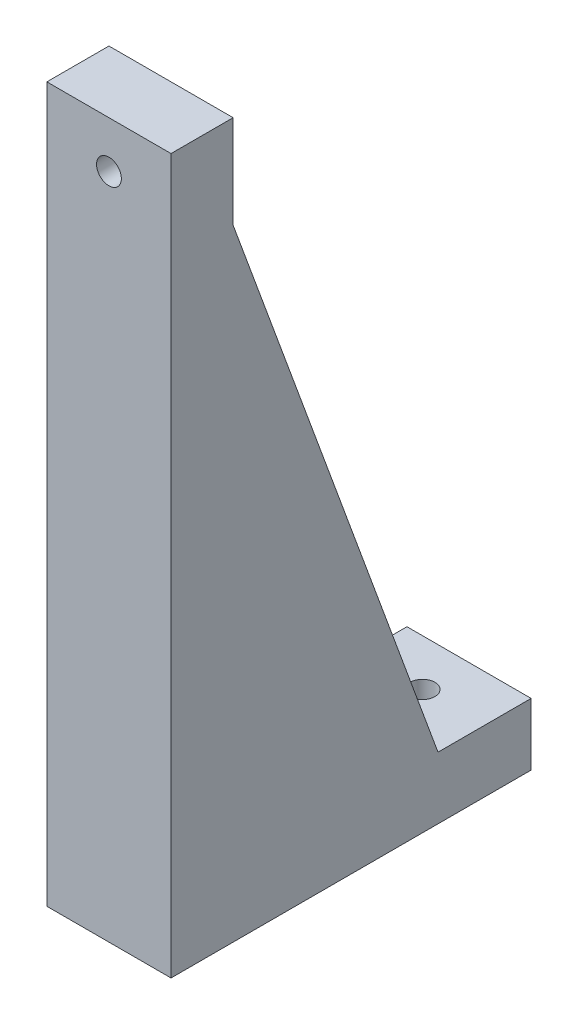
from build123d import *

# Parameters (mm, degrees)
BOSS_EXTRUDE1_DEPTH = 25.4
SKETCH2_R           = 2.54
CUT_EXTRUDE1_DEPTH  = 13.7
SKETCH3_R           = 2.54
CUT_EXTRUDE2_DEPTH  = 13.7


with BuildPart() as part:
    # Sketch1 → Boss-Extrude1 (new body)
    with BuildSketch(Plane(origin=(0, 0, 0), x_dir=(0, 0, -1), z_dir=(1, 0, 0))):
        Polygon((0, 0), (0, 146.05), (12.7, 146.05), (12.7, 127), (54.61, 12.7), (73.66, 12.7), (73.66, 0), align=None)
    extrude(amount=BOSS_EXTRUDE1_DEPTH)

    # Sketch2 → Cut-Extrude1 (cut, through all)
    with BuildSketch(Plane(origin=(0, 0, -12.7), x_dir=(-1, 0, 0), z_dir=(0, 0, -1))):
        with Locations((-12.7, 136.525)):
            Circle(SKETCH2_R)
    extrude(amount=-CUT_EXTRUDE1_DEPTH, mode=Mode.SUBTRACT)

    # Sketch3 → Cut-Extrude2 (cut, through all)
    with BuildSketch(Plane(origin=(0, 12.7, 0), x_dir=(1, 0, 0), z_dir=(0, 1, 0))):
        with Locations((12.7, 64.135)):
            Circle(SKETCH3_R)
    extrude(amount=-CUT_EXTRUDE2_DEPTH, mode=Mode.SUBTRACT)


solid = part.part
